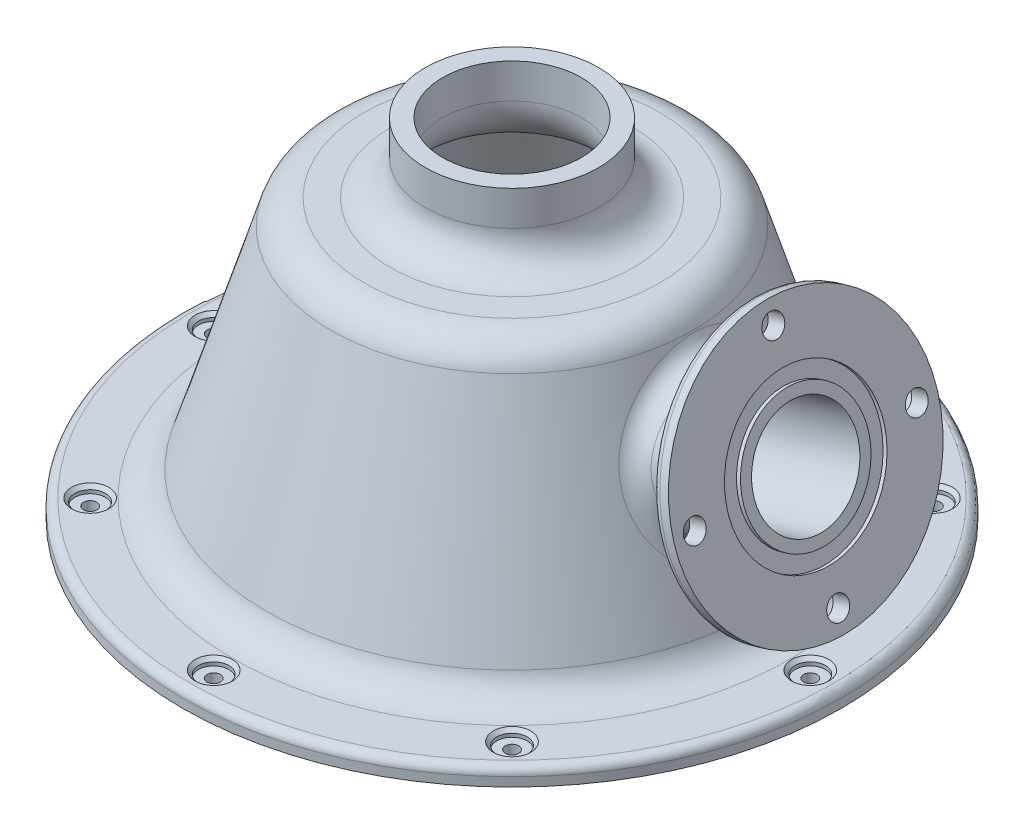
from build123d import *

# Parameters (mm, degrees)
FILLET1_R                  = 1.524
CIRPATTERN1_COUNT          = 8
FILLET2_R                  = 3.81
FILLET3_R                  = 1.524
CUT_EXTRUDE1_REACH         = 121.36
SKETCH6_R                  = 9.525
SKETCH10_R                 = 14.2875
SKETCH10_R_2               = 11.4681
CUT_EXTRUDE2_DEPTH         = 0.762
F_10_32_TAPPED_HOLE1_D     = 4.0386
F_10_32_TAPPED_HOLE1_DEPTH = 12.0396
F_10_32_TAPPED_HOLE1_TIP   = 1.213317848


with BuildPart() as part:
    # Sketch1 → Revolve1 (revolve)
    with BuildSketch(Plane.XY):
        with BuildLine():
            Line((-60.325, 0), (-60.325, 3.175))
            Line((-60.325, 3.175), (-51.009176531, 3.175))
            ThreePointArc((-51.009176531, 3.175), (-47.232051835, 4.420508935), (-44.936641331, 7.668439675))
            Line((-44.936641331, 7.668439675), (-33.123782374, 46.306560325))
            ThreePointArc((-33.123782374, 46.306560325), (-30.828371869, 49.554491065), (-27.051247174, 50.8))
            Line((-27.051247174, 50.8), (-22.225, 50.8))
            ThreePointArc((-22.225, 50.8), (-17.734871939, 52.659871939), (-15.875, 57.15))
            Line((-15.875, 57.15), (-15.875, 63.5))
            Line((-15.875, 63.5), (-12.7, 63.5))
            Line((-12.7, 63.5), (-12.7, 57.15))
            ThreePointArc((-12.7, 57.15), (-15.489807909, 50.414807909), (-22.225, 47.625))
            Line((-22.225, 47.625), (-27.051247174, 47.625))
            ThreePointArc((-27.051247174, 47.625), (-28.939809522, 47.002245532), (-30.087514774, 45.378280162))
            Line((-30.087514774, 45.378280162), (-41.90037373, 6.740159513))
            ThreePointArc((-41.90037373, 6.740159513), (-45.343489487, 1.868263403), (-51.009176531, 0))
            Line((-51.009176531, 0), (-60.325, 0))
        make_face()
    revolve(axis=Axis((0, 0, 0), (0, 1, 0)))

    # Fillet1
    fillet1_edges = [part.edges().sort_by_distance(p)[0] for p in [
        (60.325, 3.175, 0),
    ]]
    fillet(fillet1_edges, radius=FILLET1_R)

    # Sketch2 → CBORE for #2 Binding Head Machine Screw1 (revolve, cut)
    with BuildSketch(Plane(origin=(0, 3.175, -54.61), x_dir=(0, 0, 1), z_dir=(1, 0, 0))):
        Polygon((0, 0), (0, 3.175), (1.2192, 3.175), (1.2192, 1.27), (2.77876, 1.27), (2.77876, 0.635), (3.41376, 0), align=None)
    cbore_for_2_binding_head_machine_screw1 = revolve(axis=Axis((0, 9.525, -54.61), (0, -1, 0)), mode=Mode.SUBTRACT)

    # CirPattern1: CBORE for #2 Binding Head Machine Screw1 ×8 about axis
    cirpattern1_axis = Axis((0, 0, 0), (0, 1, 0))
    for i in range(1, CIRPATTERN1_COUNT):
        add(cbore_for_2_binding_head_machine_screw1.rotate(cirpattern1_axis, i * 360 / CIRPATTERN1_COUNT), mode=Mode.SUBTRACT)

    # Sketch5 → Revolve2 (revolve)
    with BuildSketch(Plane.XY):
        with BuildLine():
            Line((31.63054264, 41.539442423), (43.992848292, 45.318978554))
            ThreePointArc((43.992848292, 45.318978554), (45.867926737, 46.864673943), (46.10083573, 49.283526317))
            Line((46.10083573, 49.283526317), (43.687307308, 57.177822078))
            Line((43.687307308, 57.177822078), (46.723574908, 58.10610224))
            Line((46.723574908, 58.10610224), (53.778504143, 35.030468479))
            Line((53.778504143, 35.030468479), (35.34366329, 29.394372022))
            Line((35.34366329, 29.394372022), (31.63054264, 41.539442423))
        make_face()
    revolve(axis=Axis((0, 18.588729759, 0), (0.956304756, 0.292371705, 0)))

    # Fillet2
    fillet2_edges = [part.edges().sort_by_distance(p)[0] for p in [
        (41.755248979, 18.074305177, 0),
    ]]
    fillet(fillet2_edges, radius=FILLET2_R)

    # Fillet3
    fillet3_edges = [part.edges().sort_by_distance(p)[0] for p in [
        (57.797165778, 11.026554555, 0),
    ]]
    fillet(fillet3_edges, radius=FILLET3_R)

    # Sketch6 → Cut-Extrude1 (cut, up to next)
    with BuildSketch(Plane(origin=(58.975847026, 18.030725901, 0), x_dir=(0, 0, -1), z_dir=(0.956304756, 0.292371705, 0)), mode=Mode.PRIVATE) as cut_extrude1_sk1:
        with Locations((0, 17.776490676)):
            Circle(SKETCH6_R)
    cut_extrude1_tool1 = extrude(cut_extrude1_sk1.sketch, amount=-CUT_EXTRUDE1_REACH, mode=Mode.PRIVATE) & part.part
    add(cut_extrude1_tool1.solids().sort_by_distance((53.778504, 35.030468, 0))[0], mode=Mode.SUBTRACT)

    # Sketch10 → Cut-Extrude2 (cut)
    with BuildSketch(Plane(origin=(58.975847026, 18.030725901, 0), x_dir=(0, 0, -1), z_dir=(0.956304756, 0.292371705, 0))):
        with Locations((0, 17.776490676)):
            Circle(SKETCH10_R)
        with Locations((0, 17.776490676)):
            Circle(SKETCH10_R_2, mode=Mode.SUBTRACT)
    extrude(amount=-CUT_EXTRUDE2_DEPTH, mode=Mode.SUBTRACT)

    # #10-32 Tapped Hole1
    with Locations(Plane(origin=(58.975847026, 18.030725901, 0), x_dir=(0, 0, -1), z_dir=(0.956304756, 0.292371705, 0))):
        with Locations((-20.32, 17.776490676), (0, 38.096490676), (20.32, 17.776490676), (0, -2.543509324)):
            Hole(F_10_32_TAPPED_HOLE1_D / 2, depth=F_10_32_TAPPED_HOLE1_DEPTH)
            with Locations((0, 0, -(F_10_32_TAPPED_HOLE1_DEPTH + F_10_32_TAPPED_HOLE1_TIP / 2))):  # 118° drill point
                Cone(0, F_10_32_TAPPED_HOLE1_D / 2, F_10_32_TAPPED_HOLE1_TIP, mode=Mode.SUBTRACT)


solid = part.part
